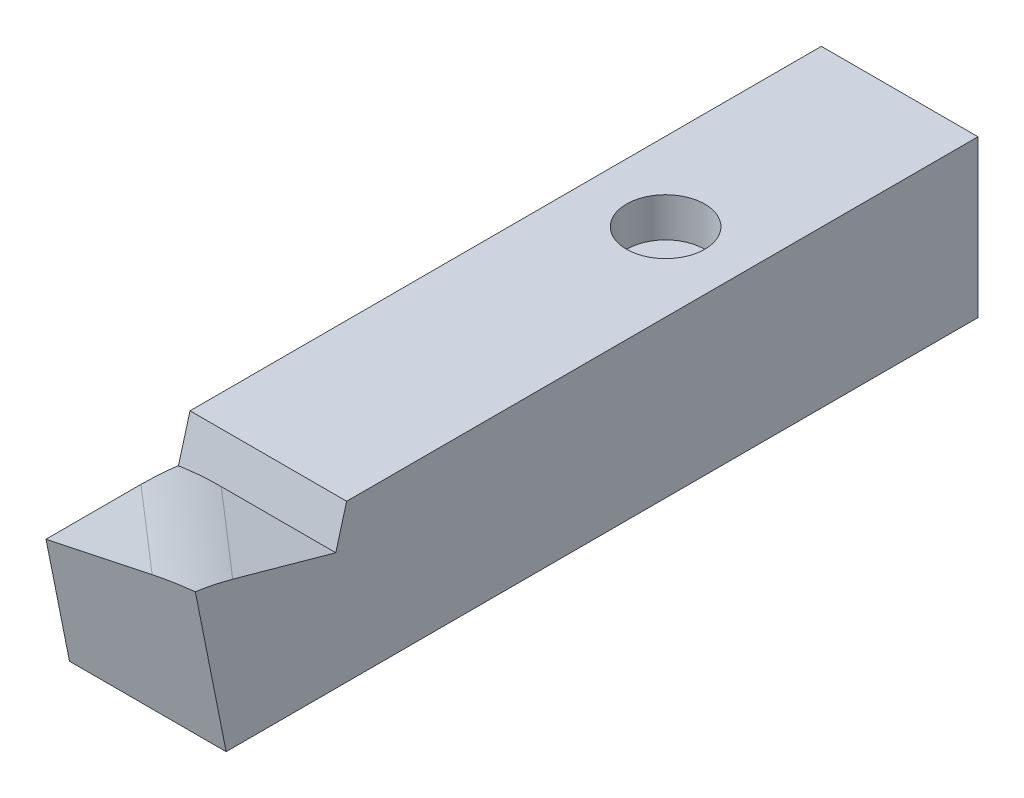
from build123d import *

# Parameters (mm, degrees)
SKETCH1_W           = 20
SKETCH1_H           = 20
BOSS_EXTRUDE1_DEPTH = 100
CUT_EXTRUDE3_DEPTH  = 20
CUT_EXTRUDE4_DEPTH  = 18
FILLET3_R           = 20
SKETCH6_R           = 5
CUT_EXTRUDE5_DEPTH  = 5


with BuildPart() as part:
    # Sketch1 → Boss-Extrude1 (new body)
    with BuildSketch(Plane.XY):
        Rectangle(SKETCH1_W, SKETCH1_H)
    extrude(amount=-BOSS_EXTRUDE1_DEPTH)

    # Sketch4 → Cut-Extrude3 (cut)
    with BuildSketch(Plane(origin=(10, 0, 0), x_dir=(0, 0, -1), z_dir=(1, 0, 0))):
        Polygon((19.388888889, 10), (0, 10), (18, 5), align=None)
        Polygon((4, -10), (0, 10), (0, -10), align=None)
    extrude(amount=-CUT_EXTRUDE3_DEPTH, mode=Mode.SUBTRACT)

    # Sketch5 → Cut-Extrude4 (cut)
    with BuildSketch(Plane.XY):
        Polygon((-10, 5), (10, 10), (-10, 10), align=None)
    extrude(amount=-CUT_EXTRUDE4_DEPTH, mode=Mode.SUBTRACT)

    # Fillet3
    fillet3_edges = [part.edges().sort_by_distance(p)[0] for p in [
        (0, 7.5, -9),
    ]]
    fillet(fillet3_edges, radius=FILLET3_R)

    # Sketch6 → Cut-Extrude5 (cut)
    with BuildSketch(Plane(origin=(0, 10, 0), x_dir=(1, 0, 0), z_dir=(0, 1, 0))):
        with Locations((0, 70.114708412)):
            Circle(SKETCH6_R)
    extrude(amount=-CUT_EXTRUDE5_DEPTH, mode=Mode.SUBTRACT)


solid = part.part
